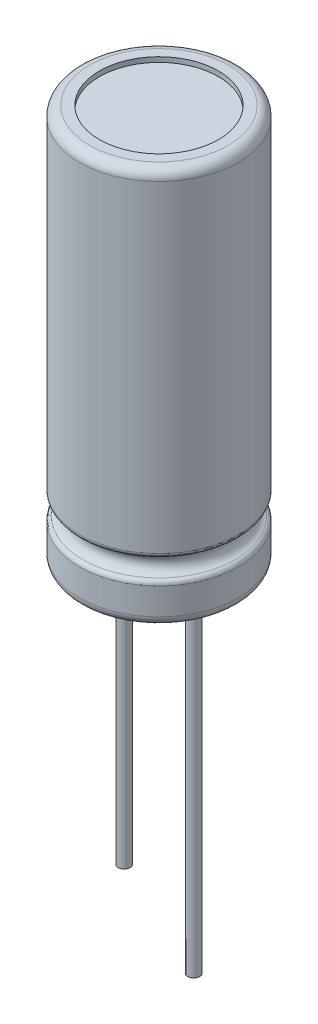
from build123d import *

# Parameters (mm, degrees)
SKETCH1_R           = 4
BASE_EXTRUDE_DEPTH  = 20
FILLET1_R           = 0.5
FILLET2_R           = 0.25
SKETCH4_R           = 3
CUT_EXTRUDE1_DEPTH  = 0.25
SKETCH3_R           = 0.3
BOSS_EXTRUDE1_DEPTH = 17.25
SKETCH5_R           = 0.3
CUT_EXTRUDE2_DEPTH  = 3
SKETCH6_R           = 3
CUT_EXTRUDE3_DEPTH  = 0.25


with BuildPart() as part:
    # Sketch1 → Base-Extrude (new body)
    with BuildSketch(Plane(origin=(0, 0, 0), x_dir=(1, 0, 0), z_dir=(0, 1, 0))):
        with Locations(Location((0, 0, 0), (0, 0, 270))):  # turned: the seam where the file's is
            Circle(SKETCH1_R)
    extrude(amount=BASE_EXTRUDE_DEPTH)

    # Sketch2 → Cut-Revolve1 (revolve, cut)
    with BuildSketch(Plane(origin=(0, 0, 0), x_dir=(0, 0, -1), z_dir=(1, 0, 0)), mode=Mode.PRIVATE) as cut_revolve1_sk:
        with BuildLine():
            Line((-4, 3.053185949), (-4, 2.053185949))
            ThreePointArc((-4, 2.053185949), (-3.5, 2.553185949), (-4, 3.053185949))
        make_face()
    revolve(cut_revolve1_sk.sketch.rotate(Axis((0, 0, 0), (0, 1, 0)), 180), axis=Axis((0, 0, 0), (0, 1, 0)), mode=Mode.SUBTRACT)  # turned: the seam where the file's is

    # Fillet1
    fillet1_edges = [part.edges().sort_by_distance(p)[0] for p in [
        (0, 0, -4),
        (0, 20, -4),
    ]]
    fillet(fillet1_edges, radius=FILLET1_R)

    # Fillet2
    fillet2_edges = [part.edges().sort_by_distance(p)[0] for p in [
        (-4, 2.053185949, 0),
        (-4, 3.053185949, 0),
    ]]
    fillet(fillet2_edges, radius=FILLET2_R)

    # Sketch4 → Cut-Extrude1 (cut)
    with BuildSketch(Plane.XZ):
        with Locations(Location((0, 0, 0), (0, 0, 270))):  # turned: the seam where the file's is
            Circle(SKETCH4_R)
    extrude(amount=-CUT_EXTRUDE1_DEPTH, mode=Mode.SUBTRACT)

    # Sketch3 → Boss-Extrude1 (add)
    with BuildSketch(Plane.XZ.offset(-0.25)):
        with Locations(Location((-1.75, 0, 0), (0, 0, 270))):  # turned: the seam where the file's is
            Circle(SKETCH3_R)
        with Locations(Location((1.75, 0, 0), (0, 0, 270))):  # turned: the seam where the file's is
            Circle(SKETCH3_R)
    extrude(amount=BOSS_EXTRUDE1_DEPTH)

    # Sketch5 → Cut-Extrude2 (cut)
    with BuildSketch(Plane.XZ.offset(17)):
        with Locations(Location((-1.75, 0, 0), (0, 0, 270))):  # turned: the seam where the file's is
            Circle(SKETCH5_R)
    extrude(amount=-CUT_EXTRUDE2_DEPTH, mode=Mode.SUBTRACT)

    # Sketch6 → Cut-Extrude3 (cut)
    with BuildSketch(Plane(origin=(0, 20, 0), x_dir=(-1, 0, 0), z_dir=(0, 1, 0))):
        with Locations(Location((0, 0, 0), (0, 0, 270))):  # turned: the seam where the file's is
            Circle(SKETCH6_R)
    extrude(amount=-CUT_EXTRUDE3_DEPTH, mode=Mode.SUBTRACT)


solid = part.part
